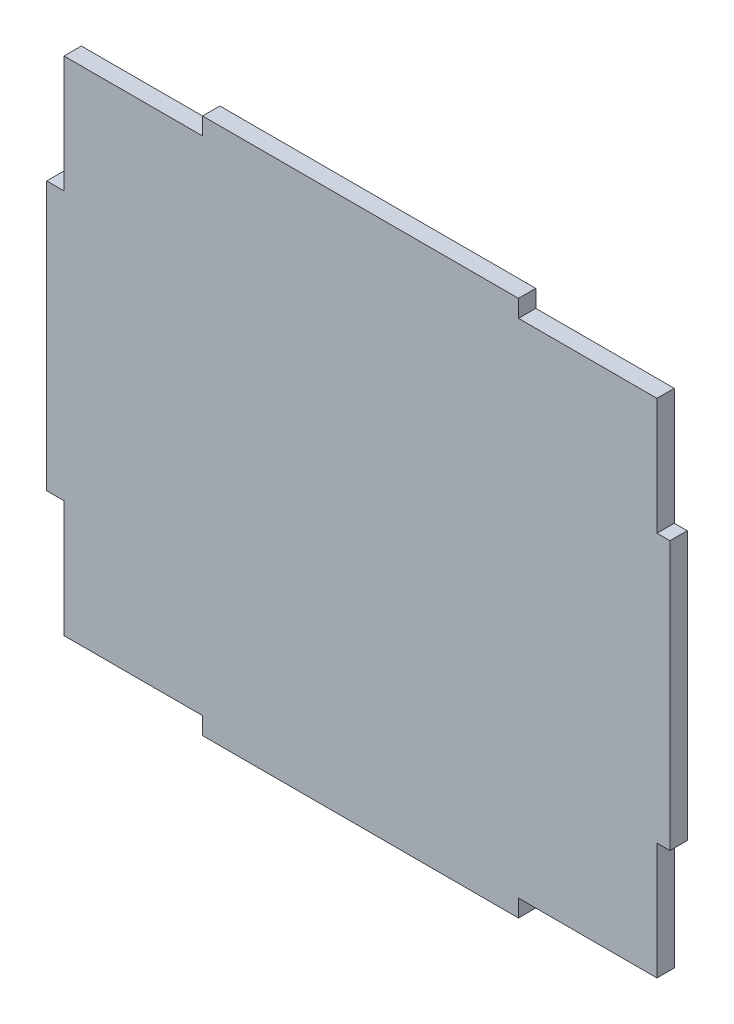
from build123d import *

# Parameters (mm, degrees)
SKETCH_1_W          = 72
SKETCH_1_H          = 62
EXTRUDE_1_DEPTH     = 2
SKETCH_2_W          = 2
SKETCH_2_H          = 15.5
CUT_EXTRUDE_1_DEPTH = 3
SKETCH_3_W          = 18
SKETCH_3_H          = 2
CUT_EXTRUDE_2_DEPTH = 3


with BuildPart() as part:
    # ｽｹｯﾁ1 → ﾎﾞｽ - 押し出し1 (new body)
    with BuildSketch(Plane.XY):
        with Locations((-1.042641223, 9.736263736)):
            Rectangle(SKETCH_1_W, SKETCH_1_H)
    extrude(amount=EXTRUDE_1_DEPTH)

    # ｽｹｯﾁ2 → ｶｯﾄ - 押し出し1 (cut, through all)
    with BuildSketch(Plane.XY.offset(2)):
        with Locations((34.457358777, -13.513736264)):
            Rectangle(SKETCH_2_W, SKETCH_2_H)
        with Locations((34.457358777, 32.986263736)):
            Rectangle(SKETCH_2_W, SKETCH_2_H)
        with Locations((-36.042641223, 32.986263736)):
            Rectangle(SKETCH_2_W, SKETCH_2_H)
        with Locations((-36.042641223, -13.513736264)):
            Rectangle(SKETCH_2_W, SKETCH_2_H)
    extrude(amount=-CUT_EXTRUDE_1_DEPTH, mode=Mode.SUBTRACT)

    # ｽｹｯﾁ3 → ｶｯﾄ - 押し出し2 (cut, through all)
    with BuildSketch(Plane.XY.offset(2)):
        with Locations((-28.042641223, 39.736263736)):
            Rectangle(SKETCH_3_W, SKETCH_3_H)
        with Locations((26.457358777, 39.736263736)):
            Rectangle(SKETCH_3_W, SKETCH_3_H)
        with Locations((-28.042641223, -20.263736264)):
            Rectangle(SKETCH_3_W, SKETCH_3_H)
        with Locations((26.457358777, -20.263736264)):
            Rectangle(SKETCH_3_W, SKETCH_3_H)
    extrude(amount=-CUT_EXTRUDE_2_DEPTH, mode=Mode.SUBTRACT)


solid = part.part
